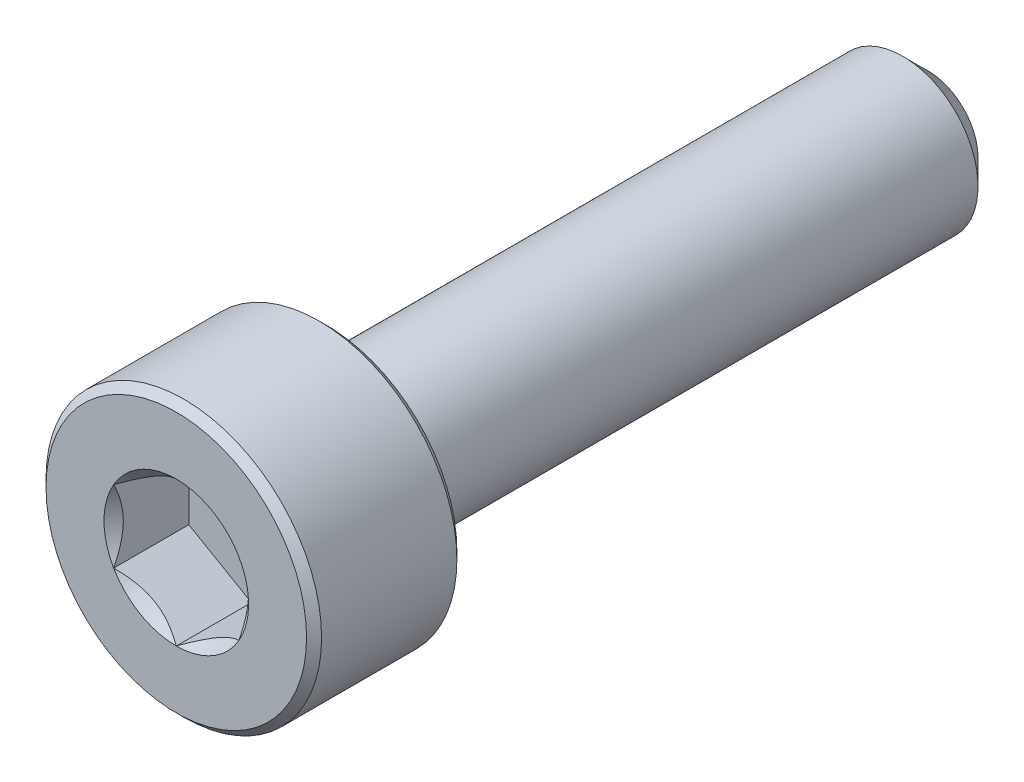
from build123d import *

# Parameters (mm, degrees)
CUT_EXTRUDE1_START = -1.5
CUT_EXTRUDE1_DEPTH = 1.5
SKETCH4_R          = 1.443375673
CUT_EXTRUDE2_DEPTH = 0.5
CUT_EXTRUDE2_TAPER = 45


with BuildPart() as part:
    # Sketch2 → Revolve1 (revolve)
    with BuildSketch(Plane(origin=(0, 0, 0), x_dir=(0, 0, -1), z_dir=(1, 0, 0))):
        Polygon((-7.35, 2.75), (-4.65, 2.75), (-4.5, 2.6), (-4.5, 1.5), (7, 1.5), (7.5, 1), (7.5, 0), (-7.5, 0), (-7.5, 2.6), align=None)
    revolve(axis=Axis((0, 0, -7.5), (0, 0, 1)))

    # Sketch3 → Cut-Extrude1 (cut)
    with BuildSketch(Plane.XY.offset(7.5).offset(CUT_EXTRUDE1_START)):
        Polygon((0, 1.443375673), (-1.25, 0.721687836), (-1.25, -0.721687836), (0, -1.443375673), (1.25, -0.721687836), (1.25, 0.721687836), align=None)
    extrude(amount=CUT_EXTRUDE1_DEPTH, mode=Mode.SUBTRACT)

    # Sketch4 → Cut-Extrude2 (cut)
    with BuildSketch(Plane.XY.offset(7.5)):
        Circle(SKETCH4_R)
    extrude(amount=-CUT_EXTRUDE2_DEPTH, taper=CUT_EXTRUDE2_TAPER, mode=Mode.SUBTRACT)


solid = part.part
